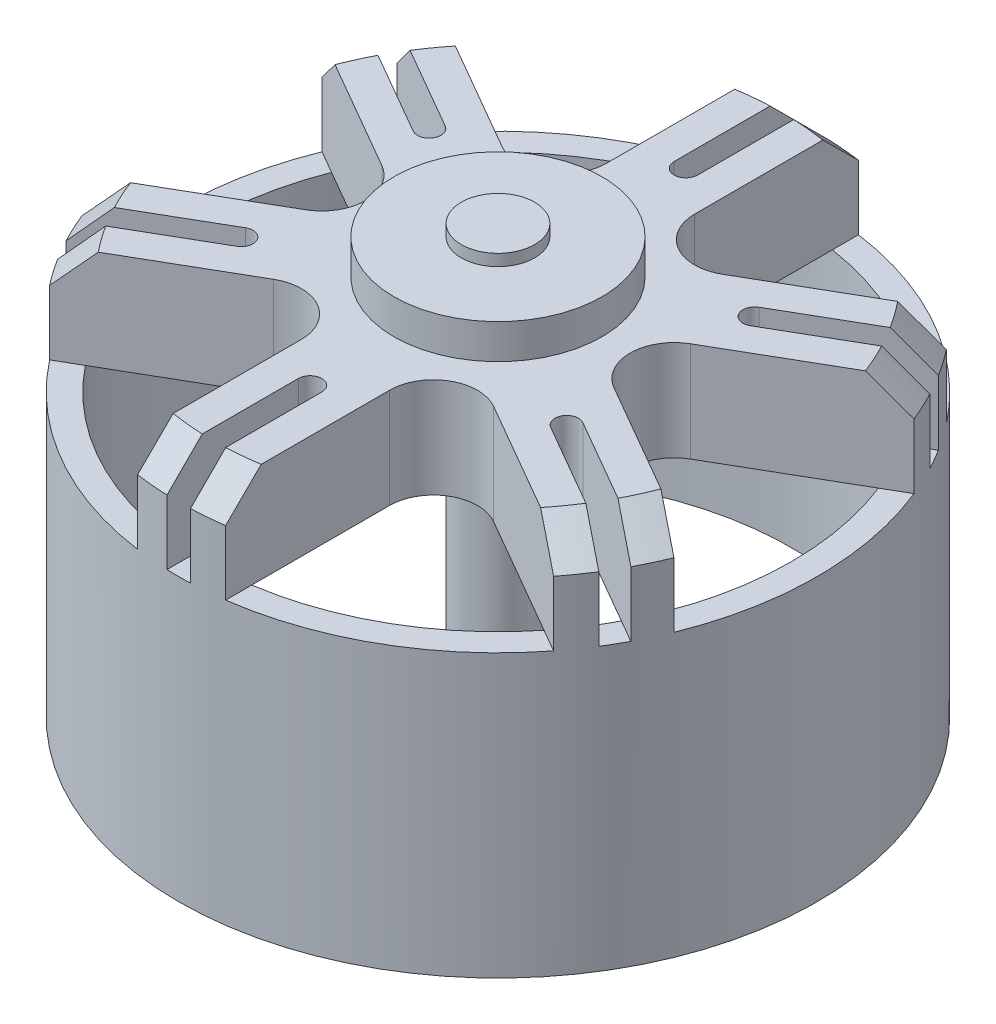
from build123d import *

# Parameters (mm, degrees)
SKETCH1_R                = 13.8176
SKETCH1_R_2              = 12.7
BOSS_EXTRUDE1_DEPTH      = 16.5
SKETCH2_R                = 13.8176
BOSS_EXTRUDE2_DEPTH      = 4.318
CUT_EXTRUDE1_DEPTH       = 4.318
CIRPATTERN1_COUNT        = 6
CHAMFER1_SIZE            = 1.524
SKETCH4_R                = 4.5
BOSS_EXTRUDE3_DEPTH      = 1.5
SKETCH5_R                = 1.5875
BOSS_EXTRUDE4_DEPTH      = 0.5
BOSS_EXTRUDE4_DEPTH_BACK = 26


with BuildPart() as part:
    # Sketch1 → Boss-Extrude1 (new body)
    with BuildSketch(Plane(origin=(0, 0, 0), x_dir=(1, 0, 0), z_dir=(0, 1, 0))):
        with Locations(Location((0, 0, 0), (0, 0, 270))):  # turned: the seam where the file's is
            Circle(SKETCH1_R)
        with Locations(Location((0, 0, 0), (0, 0, 270))):  # turned: the seam where the file's is
            Circle(SKETCH1_R_2, mode=Mode.SUBTRACT)
    extrude(amount=BOSS_EXTRUDE1_DEPTH)

    # Sketch2 → Boss-Extrude2 (add)
    with BuildSketch(Plane(origin=(0, 16.5, 0), x_dir=(-1, 0, 0), z_dir=(0, 1, 0))):
        with Locations(Location((0, 0, 0), (0, 0, 90))):  # turned: the seam where the file's is
            Circle(SKETCH2_R)
    extrude(amount=-BOSS_EXTRUDE2_DEPTH)

    # Sketch3 → Cut-Extrude1 (cut)
    with BuildSketch(Plane(origin=(0, 16.5, 0), x_dir=(-1, 0, 0), z_dir=(0, 1, 0))):
        with BuildLine():
            Line((-1.905, -13.685651054), (-1.905, -6.599113577))
            ThreePointArc((-1.905, -6.599113577), (-2.8575, -4.949335183), (-4.7625, -4.949335183))
            Line((-4.7625, -4.949335183), (-10.89962148, -8.492603921))
            ThreePointArc((-10.89962148, -8.492603921), (-6.9088, -11.966392619), (-1.905, -13.685651054))
        make_face()
        with BuildLine():
            Line((-0.508, -13.808258607), (-0.508, -8.128))
            ThreePointArc((-0.508, -8.128), (-0.359210245, -7.768789755), (0, -7.62))
            Line((0, -7.62), (0, -13.8176))
            ThreePointArc((0, -13.8176), (-0.25404294, -13.815264454), (-0.508, -13.808258607))
        make_face()
        with BuildLine():
            Line((-11.704302736, -7.344070209), (-6.785054482, -4.503940905))
            ThreePointArc((-6.785054482, -4.503940905), (-6.548364162, -4.195480075), (-6.599113577, -3.81))
            Line((-6.599113577, -3.81), (-11.966392619, -6.9088))
            ThreePointArc((-11.966392619, -6.9088), (-11.837348507, -7.127639867), (-11.704302736, -7.344070209))
        make_face()
    cut_extrude1 = extrude(amount=-CUT_EXTRUDE1_DEPTH, mode=Mode.SUBTRACT)

    # CirPattern1: Cut-Extrude1 ×6 about axis
    cirpattern1_axis = Axis((0, 0, 0), (0, 1, 0))
    for i in range(1, CIRPATTERN1_COUNT):
        add(cut_extrude1.rotate(cirpattern1_axis, i * 360 / CIRPATTERN1_COUNT), mode=Mode.SUBTRACT)

    # Chamfer1
    chamfer1_edges = [part.edges().sort_by_distance(p)[0] for p in [
        (-12.524598769, 16.5, 5.83613703),
        (-11.316542312, 16.5, 7.928552191),
        (-1.208056457, 16.5, 13.764689221),
        (1.208056457, 16.5, 13.764689221),
        (1.208056457, 16.5, -13.764689221),
        (11.316542312, 16.5, 7.928552191),
        (12.524598769, 16.5, 5.83613703),
        (12.524598769, 16.5, -5.83613703),
        (11.316542312, 16.5, -7.928552191),
        (-11.316542312, 16.5, -7.928552191),
        (-12.524598769, 16.5, -5.83613703),
        (-1.208056457, 16.5, -13.764689221),
    ]]
    chamfer(chamfer1_edges, length=CHAMFER1_SIZE)

    # Sketch4 → Boss-Extrude3 (add)
    with BuildSketch(Plane(origin=(0, 16.5, 0), x_dir=(-1, 0, 0), z_dir=(0, 1, 0))):
        with Locations(Location((0, 0, 0), (0, 0, 90))):  # turned: the seam where the file's is
            Circle(SKETCH4_R)
    extrude(amount=BOSS_EXTRUDE3_DEPTH)

    # Sketch5 → Boss-Extrude4 (add, two sides)
    with BuildSketch(Plane(origin=(0, 18, 0), x_dir=(-1, 0, 0), z_dir=(0, 1, 0))) as boss_extrude4_sk:
        with Locations(Location((0, 0, 0), (0, 0, 90))):  # turned: the seam where the file's is
            Circle(SKETCH5_R)
    extrude(amount=BOSS_EXTRUDE4_DEPTH)
    extrude(boss_extrude4_sk.sketch, amount=-BOSS_EXTRUDE4_DEPTH_BACK)


solid = part.part
